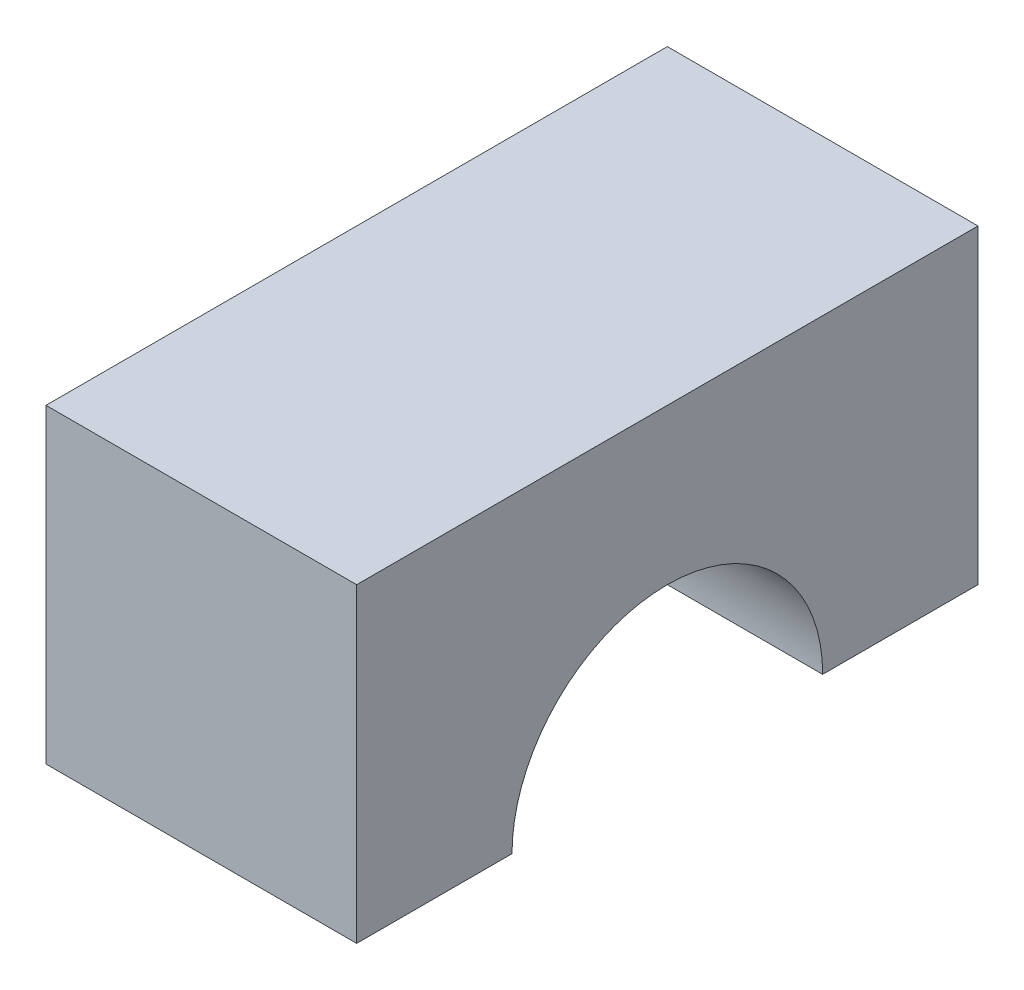
from build123d import *

# Parameters (mm, degrees)
BOSS_EXTRUDE1_DEPTH = 25.4


with BuildPart() as part:
    # Sketch1 → Boss-Extrude1 (new body)
    with BuildSketch(Plane(origin=(0, 0, 0), x_dir=(0, 0, -1), z_dir=(1, 0, 0))):
        with BuildLine():
            Line((0, 25.4), (0, 0))
            Line((0, 0), (2.459031877, 0))
            Line((2.459031877, 0), (12.7, 0))
            ThreePointArc((12.7, 0), (25.4, 12.7), (38.1, 0))
            Line((38.1, 0), (50.8, 0))
            Line((50.8, 0), (50.8, 25.4))
            Line((50.8, 25.4), (0, 25.4))
        make_face()
    extrude(amount=BOSS_EXTRUDE1_DEPTH)


solid = part.part
